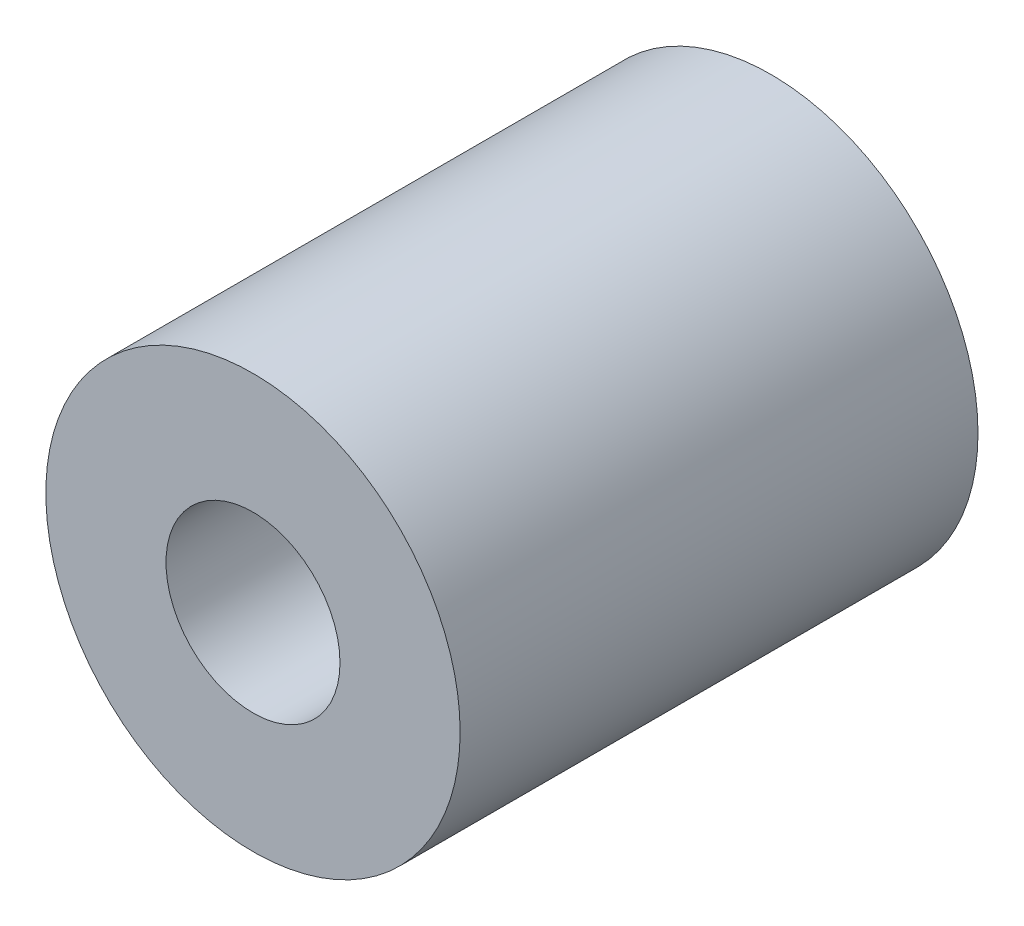
from build123d import *

# Parameters (mm, degrees)
CROQUIS1_R                   = 10
SALIENTE_EXTRUIR1_DEPTH      = 25
TALADRO_DE_MARGEN_PARA_M81_D = 8.4


with BuildPart() as part:
    # Croquis1 → Saliente-Extruir1 (new body)
    with BuildSketch(Plane.XY):
        Circle(CROQUIS1_R)
    extrude(amount=SALIENTE_EXTRUIR1_DEPTH)

    # Taladro de margen para M81 (through all)
    with Locations(Plane.XY.offset(25)):
        with Locations((0, 0)):
            Hole(TALADRO_DE_MARGEN_PARA_M81_D / 2)


solid = part.part
